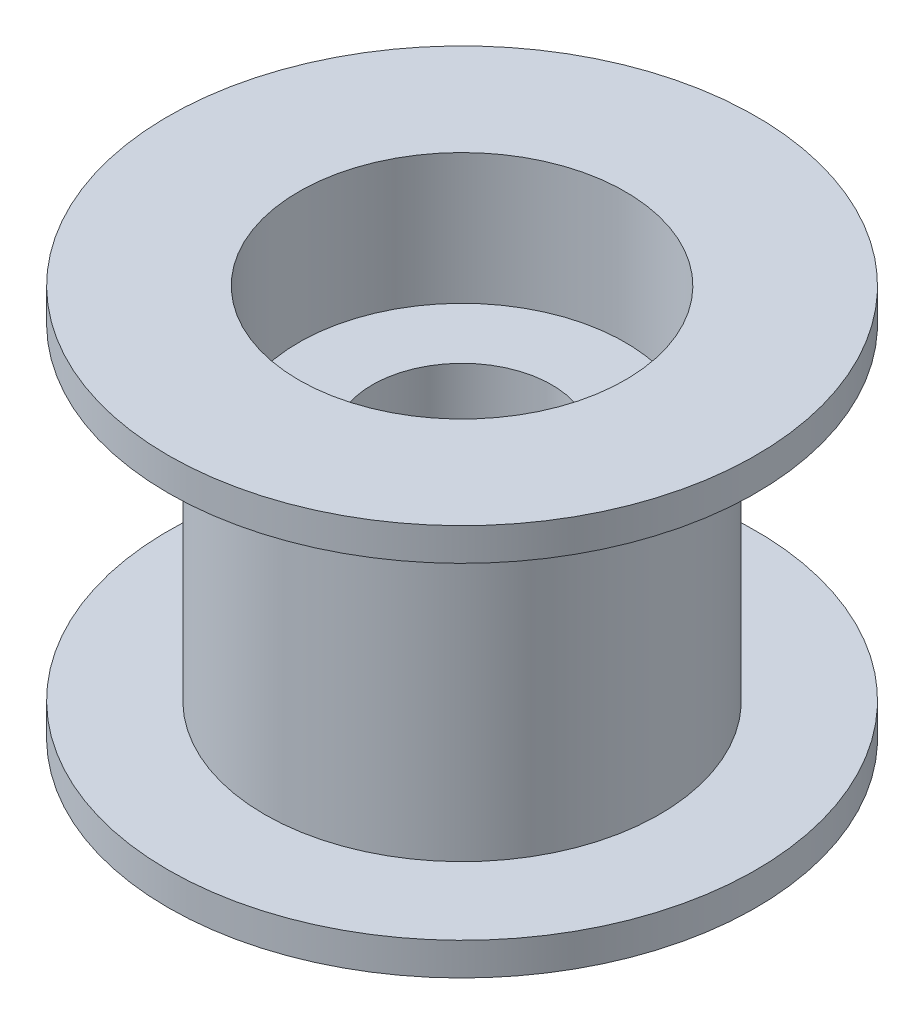
from build123d import *


with BuildPart() as part:
    # Sketch1 → Revolve1 (revolve)
    with BuildSketch(Plane.XY):
        Polygon((-5, 6), (-9, 6), (-9, 5), (-6.05, 5), (-6.05, -5), (-9, -5), (-9, -6), (-5, -6), (-5, -2), (-2.75, -2), (-2.75, 2), (-5, 2), align=None)
    revolve(axis=Axis((0, 6, 0), (0, -1, 0)))


solid = part.part
